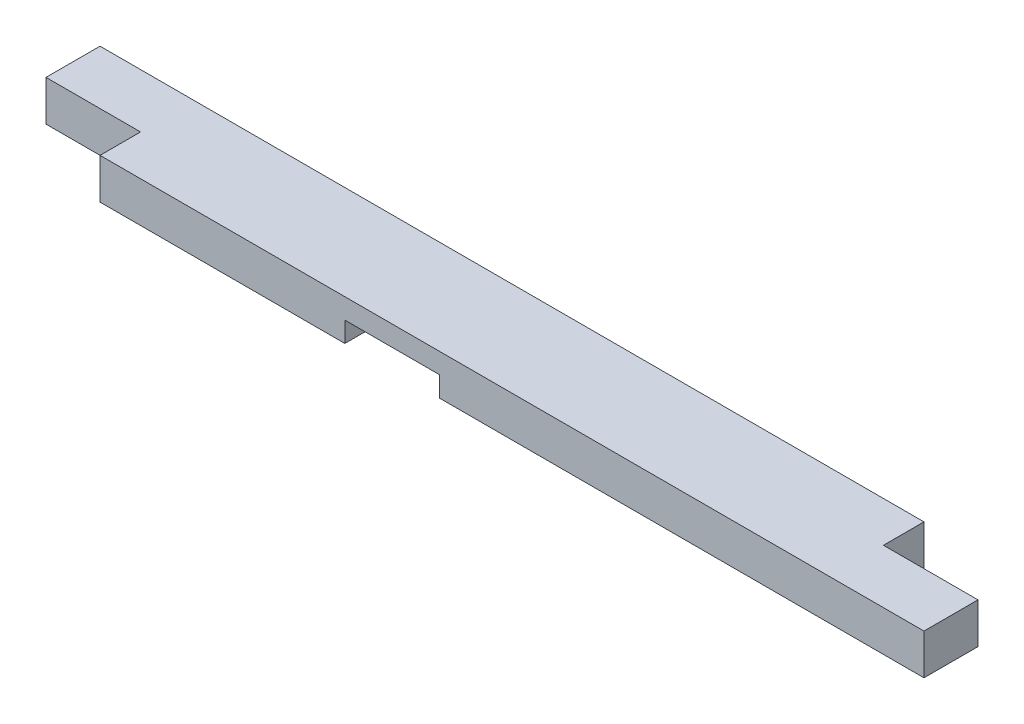
from build123d import *

# Parameters (mm, degrees)
SKETCH1_W           = 863.6
SKETCH1_H           = 88.9
BOSS_EXTRUDE1_DEPTH = 38.1
SKETCH2_W           = 88.9
SKETCH2_H           = 88.9
CUT_EXTRUDE1_DEPTH  = 19.05
SKETCH3_W           = 88.9
SKETCH3_H           = 38.1
CUT_EXTRUDE2_DEPTH  = 39.1
SKETCH4_W           = 88.9
SKETCH4_H           = 38.1
CUT_EXTRUDE3_DEPTH  = 39.1


with BuildPart() as part:
    # Sketch1 → Boss-Extrude1 (new body)
    with BuildSketch(Plane(origin=(0, 0, 0), x_dir=(1, 0, 0), z_dir=(0, 1, 0))):
        with Locations((431.8, 44.45)):
            Rectangle(SKETCH1_W, SKETCH1_H)
    extrude(amount=BOSS_EXTRUDE1_DEPTH)

    # Sketch2 → Cut-Extrude1 (cut)
    with BuildSketch(Plane.XZ):
        with Locations((363.5375, -44.45)):
            Rectangle(SKETCH2_W, SKETCH2_H)
    extrude(amount=-CUT_EXTRUDE1_DEPTH, mode=Mode.SUBTRACT)

    # Sketch3 → Cut-Extrude2 (cut, through all)
    with BuildSketch(Plane(origin=(0, 38.1, 0), x_dir=(1, 0, 0), z_dir=(0, 1, 0))):
        with Locations((44.45, 19.05)):
            Rectangle(SKETCH3_W, SKETCH3_H)
    extrude(amount=-CUT_EXTRUDE2_DEPTH, mode=Mode.SUBTRACT)

    # Sketch4 → Cut-Extrude3 (cut, through all)
    with BuildSketch(Plane(origin=(0, 38.1, 0), x_dir=(1, 0, 0), z_dir=(0, 1, 0))):
        with Locations((819.15, 69.85)):
            Rectangle(SKETCH4_W, SKETCH4_H)
    extrude(amount=-CUT_EXTRUDE3_DEPTH, mode=Mode.SUBTRACT)


solid = part.part
